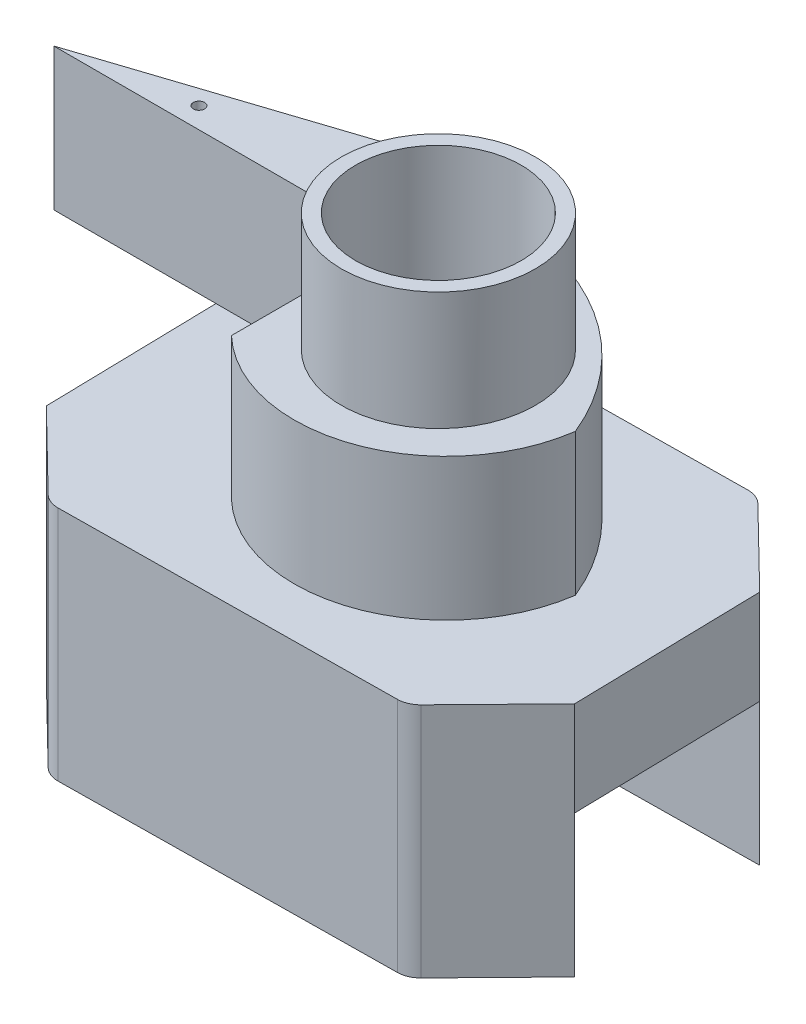
from build123d import *

# Parameters (mm, degrees)
BOSS_EXTRUDE2_DEPTH = 10
CUT_EXTRUDE2_DEPTH  = 6
BOSS_EXTRUDE4_DEPTH = 6
SKETCH6_R           = 4.1
BOSS_EXTRUDE5_DEPTH = 5
SKETCH8_R           = 3.5
CUT_EXTRUDE3_DEPTH  = 15
SKETCH9_R           = 0.238796938
CUT_EXTRUDE4_DEPTH  = 5
FILLET3_R           = 1
FILLET5_R           = 1


with BuildPart() as part:
    # Sketch1 → Boss-Extrude2 (new body)
    with BuildSketch(Plane(origin=(0, 0, 0), x_dir=(1, 0, 0), z_dir=(0, 1, 0))):
        Polygon((8.212445626, 7.40100076), (-6.787554374, 7.224195263), (-10.281169213, 3.647233513), (-10.104363716, -4.352766487), (-6.527401966, -7.846381326), (8.472598034, -7.669575828), (11.966212872, -4.092614079), (11.789407375, 3.907385921), align=None)
    extrude(amount=BOSS_EXTRUDE2_DEPTH)

    # Sketch4 → Cut-Extrude2 (cut)
    with BuildSketch(Plane(origin=(0, 0, 0), x_dir=(1, 0, 0), z_dir=(0, 1, 0))):
        Polygon((-10.281169213, 3.647233513), (11.789407375, 3.907385921), (11.966212872, -4.092614079), (-10.104363716, -4.352766487), align=None)
    extrude(amount=CUT_EXTRUDE2_DEPTH, mode=Mode.SUBTRACT)

    # Sketch5 → Boss-Extrude4 (add)
    with BuildSketch(Plane(origin=(0, 10, 0), x_dir=(1, 0, 0), z_dir=(0, 1, 0))):
        with BuildLine():
            Line((-17.121590923, 2.980762336), (-4.095095114, 7.255931369))
            ThreePointArc((-4.095095114, 7.255931369), (-3.125179525, 7.071252821), (-2.766206415, 6.151480718))
            ThreePointArc((-2.766206415, 6.151480718), (3.686890427, 4.860901674), (8.008746735, -0.10192123))
            ThreePointArc((8.008746735, -0.10192123), (3.769808673, -5.271440115), (-2.766206415, -3.866794904))
            Line((-2.766206415, -3.866794904), (-2.766206415, 2.980762336))
            Line((-2.766206415, 2.980762336), (-17.121590923, 2.980762336))
        make_face()
    extrude(amount=BOSS_EXTRUDE4_DEPTH)

    # Sketch6 → Boss-Extrude5 (add)
    with BuildSketch(Plane(origin=(0, 16, 0), x_dir=(1, 0, 0), z_dir=(0, 1, 0))):
        with Locations((2.116284808, 0)):
            Circle(SKETCH6_R)
    extrude(amount=BOSS_EXTRUDE5_DEPTH)

    # Sketch8 → Cut-Extrude3 (cut)
    with BuildSketch(Plane(origin=(0, 21, 0), x_dir=(1, 0, 0), z_dir=(0, 1, 0))):
        with Locations((2.116284808, 0)):
            Circle(SKETCH8_R)
    extrude(amount=-CUT_EXTRUDE3_DEPTH, mode=Mode.SUBTRACT)

    # Sketch9 → Cut-Extrude4 (cut)
    with BuildSketch(Plane(origin=(0, 16, 0), x_dir=(1, 0, 0), z_dir=(0, 1, 0))):
        with Locations((-11.868205528, 3.862890266)):
            Circle(SKETCH9_R)
    extrude(amount=-CUT_EXTRUDE4_DEPTH, mode=Mode.SUBTRACT)

    # Fillet3
    fillet3_edges = [part.edges().sort_by_distance(p)[0] for p in [
        (8.472598034, 5, 7.669575828),
    ]]
    fillet(fillet3_edges, radius=FILLET3_R)

    # Fillet5
    fillet5_edges = [part.edges().sort_by_distance(p)[0] for p in [
        (-6.527401966, 5, 7.846381326),
        (-6.787554374, 5, -7.224195263),
        (8.212445626, 5, -7.40100076),
    ]]
    fillet(fillet5_edges, radius=FILLET5_R)


solid = part.part
